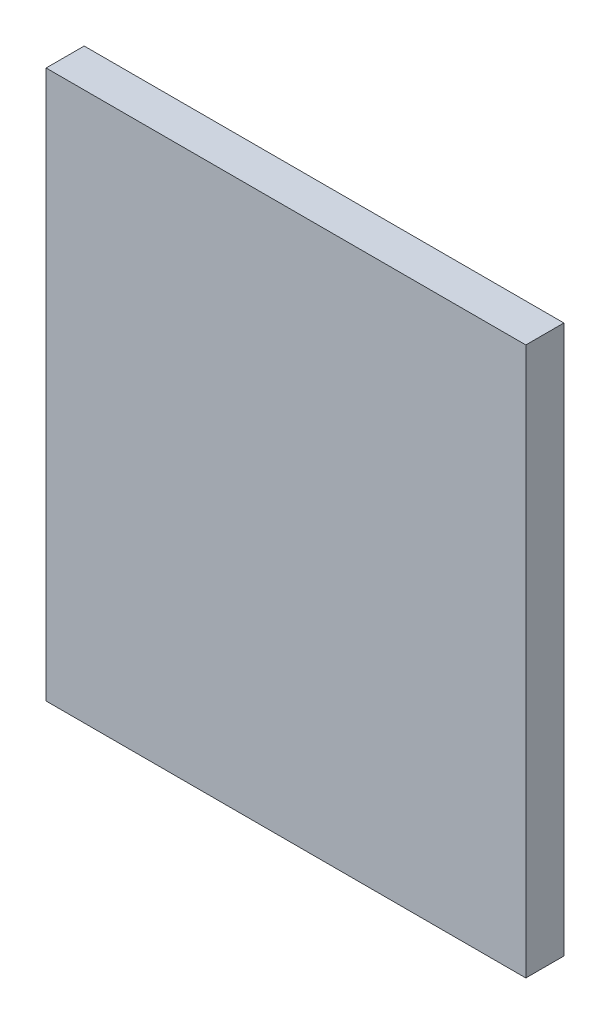
from build123d import *

# Parameters (mm, degrees)
SKETCH5_W           = 63
SKETCH5_H           = 72
BOSS_EXTRUDE2_DEPTH = 5


with BuildPart() as part:
    # Sketch5 → Boss-Extrude2 (new body)
    with BuildSketch(Plane.XY):
        with Locations((0, 6)):
            Rectangle(SKETCH5_W, SKETCH5_H)
    extrude(amount=BOSS_EXTRUDE2_DEPTH)


solid = part.part
